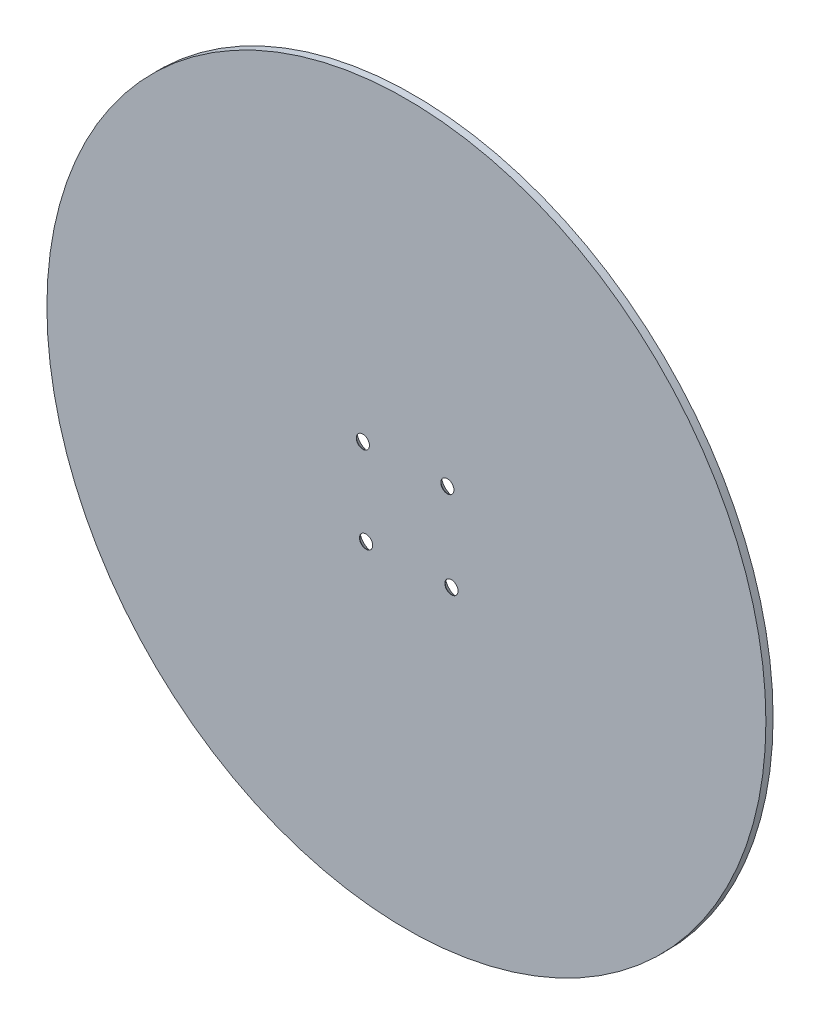
from build123d import *

# Parameters (mm, degrees)
SKETCH1_R                    = 150
BOSS_EXTRUDE1_DEPTH          = 3
CSK_FOR_M5_SFHCS1_AT_2_COUNT = 2
CSK_FOR_M5_SFHCS1_AT_2_PITCH = 35.289297711
CSK_FOR_M5_SFHCS1_AT_3_COUNT = 2
CSK_FOR_M5_SFHCS1_AT_3_PITCH = 50.17586669
CSK_FOR_M5_SFHCS1_AT_4_COUNT = 2
CSK_FOR_M5_SFHCS1_AT_4_PITCH = 35.678748885


with BuildPart() as part:
    # Sketch1 → Boss-Extrude1 (new body)
    with BuildSketch(Plane.XY):
        Circle(SKETCH1_R)
    extrude(amount=BOSS_EXTRUDE1_DEPTH)

    # Sketch4 → CSK for M5 SFHCS1 (revolve, cut)
    with BuildSketch(Plane(origin=(17.080766051, 18.586987198, 0), x_dir=(0, 1, 0), z_dir=(1, 0, 0))):
        Polygon((0, 0), (0, 3), (2.75, 3), (2.75, 2.85), (5.6, 0), align=None)
    csk_for_m5_sfhcs1 = revolve(axis=Axis((17.080766051, 18.586987198, -6.35), (0, 0, 1)), mode=Mode.SUBTRACT)

    # CSK for M5 SFHCS1 at 2: CSK for M5 SFHCS1 ×2
    with Locations(*[Vector(-0.99906632, -0.043202868, 0) * (i * CSK_FOR_M5_SFHCS1_AT_2_PITCH) for i in range(1, CSK_FOR_M5_SFHCS1_AT_2_COUNT)]):
        add(csk_for_m5_sfhcs1, mode=Mode.SUBTRACT)

    # CSK for M5 SFHCS1 at 3: CSK for M5 SFHCS1 ×2
    with Locations(*[Vector(-0.676068537, -0.736838743, 0) * (i * CSK_FOR_M5_SFHCS1_AT_3_PITCH) for i in range(1, CSK_FOR_M5_SFHCS1_AT_3_COUNT)]):
        add(csk_for_m5_sfhcs1, mode=Mode.SUBTRACT)

    # CSK for M5 SFHCS1 at 4: CSK for M5 SFHCS1 ×2
    with Locations(*[Vector(0.048072698, -0.998843839, 0) * (i * CSK_FOR_M5_SFHCS1_AT_4_PITCH) for i in range(1, CSK_FOR_M5_SFHCS1_AT_4_COUNT)]):
        add(csk_for_m5_sfhcs1, mode=Mode.SUBTRACT)


solid = part.part
